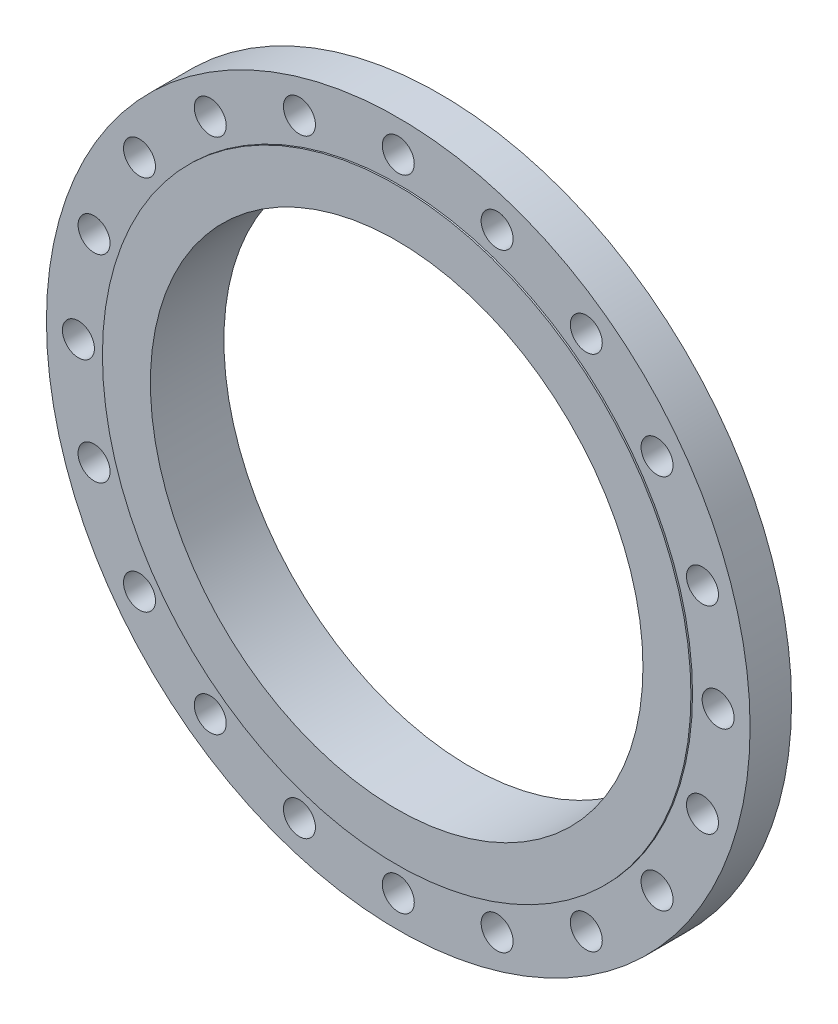
from build123d import *

# Parameters (mm, degrees)
SKETCH1_R           = 11.5
BOSS_EXTRUDE1_DEPTH = 1.6825
SKETCH1_5_R         = 9.625
CUT_EXTRUDE1_DEPTH  = 3.6825
SKETCH1_6_R         = 13.75
BOSS_EXTRUDE2_DEPTH = 1.62
SKETCH1_7_R         = 9.625
CUT_EXTRUDE2_DEPTH  = 14.62
SKETCH7_R           = 0.625
CUT_EXTRUDE5_DEPTH  = 58.62
CIRPATTERN1_COUNT   = 20
BOSS_EXTRUDE3_START = -1.19
SKETCH1_8_R         = 11.5
BOSS_EXTRUDE3_DEPTH = 1.19
CUT_EXTRUDE6_START  = -19.19
SKETCH1_9_R         = 9.625
CUT_EXTRUDE6_DEPTH  = 19.19
SCALE1_SCALE        = 25.4


with BuildPart() as part:
    # Sketch1 → Boss-Extrude1 (new body)
    with BuildSketch(Plane.XY):
        Circle(SKETCH1_R)
    extrude(amount=BOSS_EXTRUDE1_DEPTH)

    # Sketch1_5 → Cut-Extrude1 (cut)
    with BuildSketch(Plane.XY):
        Circle(SKETCH1_5_R)
    extrude(amount=CUT_EXTRUDE1_DEPTH, mode=Mode.SUBTRACT)

    # Sketch1_6 → Boss-Extrude2 (add)
    with BuildSketch(Plane.XY):
        Circle(SKETCH1_6_R)
    extrude(amount=BOSS_EXTRUDE2_DEPTH)

    # Sketch1_7 → Cut-Extrude2 (cut)
    with BuildSketch(Plane.XY):
        Circle(SKETCH1_7_R)
    extrude(amount=CUT_EXTRUDE2_DEPTH, mode=Mode.SUBTRACT)

    # Sketch7 → Cut-Extrude5 (cut)
    with BuildSketch(Plane.XY):
        with Locations((0, 12.5)):
            Circle(SKETCH7_R)
    cut_extrude5 = extrude(amount=CUT_EXTRUDE5_DEPTH, mode=Mode.SUBTRACT)

    # CirPattern1: Cut-Extrude5 ×20 about axis
    cirpattern1_axis = Axis((0, 0, 0), (0, 0, 1))
    for i in range(1, CIRPATTERN1_COUNT):
        add(cut_extrude5.rotate(cirpattern1_axis, i * 360 / CIRPATTERN1_COUNT), mode=Mode.SUBTRACT)

    # Sketch1_8 → Boss-Extrude3 (add)
    with BuildSketch(Plane.XY.offset(BOSS_EXTRUDE3_START)):
        Circle(SKETCH1_8_R)
    extrude(amount=BOSS_EXTRUDE3_DEPTH)

    # Sketch1_9 → Cut-Extrude6 (cut)
    with BuildSketch(Plane.XY.offset(CUT_EXTRUDE6_START)):
        Circle(SKETCH1_9_R)
    extrude(amount=CUT_EXTRUDE6_DEPTH, mode=Mode.SUBTRACT)


with BuildPart() as part_1:
    # Scale1: scaled about (0, 0, 0.477928167)
    add(part.part.scale(SCALE1_SCALE).moved(Location((0, 0, -11.661447275))))


solid = part_1.part
